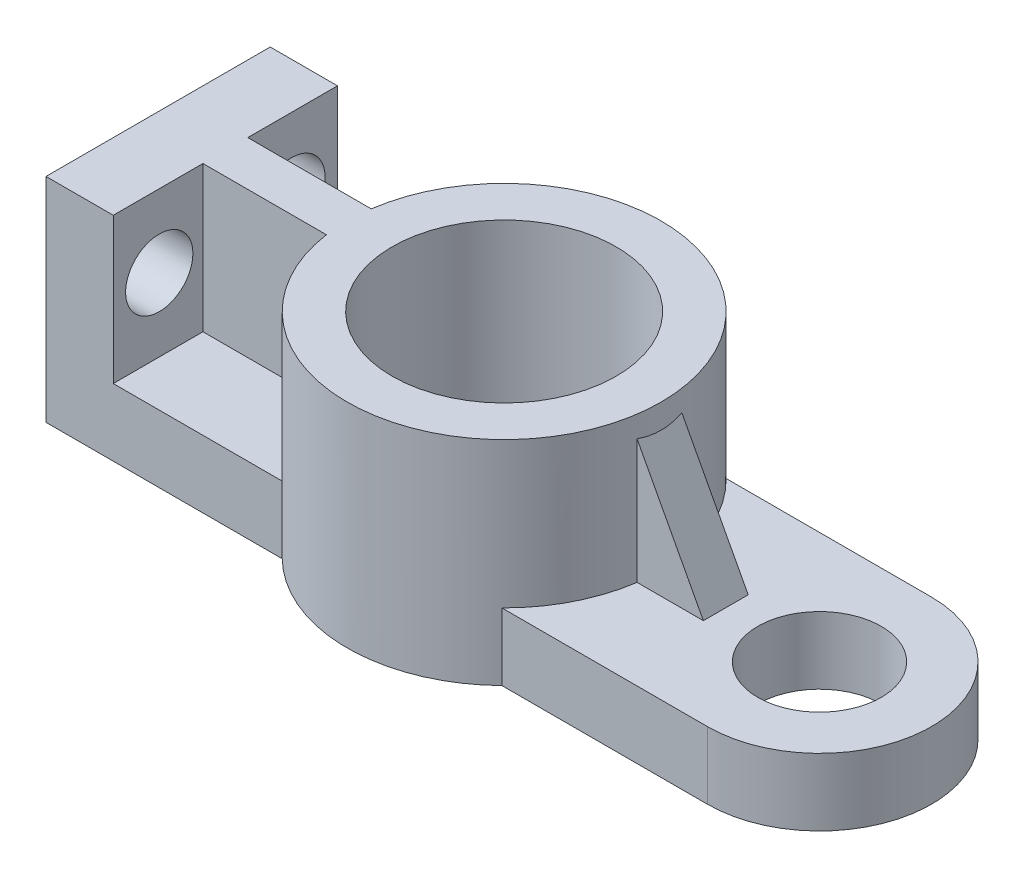
from build123d import *

# Parameters (mm, degrees)
EXTRUDE_THIN1_DEPTH      = 100
SKETCH2_W                = 50
SKETCH2_H                = 30
REVOLVE1_ANGLE           = 180
SKETCH3_R                = 27.5
CUT_EXTRUDE1_DEPTH       = 351.89172119
CUT_EXTRUDE1_DEPTH_BACK  = 351.89172119
SKETCH4_R                = 70
BOSS_EXTRUDE1_DEPTH      = 65
BOSS_EXTRUDE1_DEPTH_BACK = 30
SKETCH5_R                = 50
CUT_EXTRUDE2_DEPTH       = 364.765034054
SKETCH6_R                = 15
CUT_EXTRUDE3_DEPTH       = 347.446244026
RIB1_REACH               = 348.699
SKETCH8_WALL_W           = 749.740096374
SKETCH8_WALL_H           = 20
RIB23_REACH              = 348.699
SKETCH15_WALL_W          = 778.361425474
SKETCH15_WALL_H          = 20


with BuildPart() as part:
    # Sketch1 → Extrude-Thin1 (new body)
    with BuildSketch(Plane.XY):
        Polygon((-15, 80), (-15, -15), (280, -15), (280, 15), (15, 15), (15, 80), align=None)
    extrude(amount=EXTRUDE_THIN1_DEPTH)

    # Sketch2 → Revolve1 (revolve)
    with BuildSketch(Plane(origin=(280, 0, 0), x_dir=(0, 0, -1), z_dir=(1, 0, 0))):
        with Locations((-75, 0)):
            Rectangle(SKETCH2_W, SKETCH2_H)
    revolve(axis=Axis((280, 15, 50), (0, 1, 0)), revolution_arc=REVOLVE1_ANGLE)

    # Sketch3 → Cut-Extrude1 (cut, two sides)
    with BuildSketch(Plane(origin=(0, 15, 0), x_dir=(1, 0, 0), z_dir=(0, 1, 0))) as cut_extrude1_sk:
        with Locations(Location((280, -50, 0), (0, 0, 270))):
            Circle(SKETCH3_R)
    extrude(amount=CUT_EXTRUDE1_DEPTH, mode=Mode.SUBTRACT)
    extrude(cut_extrude1_sk.sketch, amount=-CUT_EXTRUDE1_DEPTH_BACK, mode=Mode.SUBTRACT)

    # Sketch4 → Boss-Extrude1 (add, two sides)
    with BuildSketch(Plane(origin=(0, 15, 0), x_dir=(1, 0, 0), z_dir=(0, 1, 0))) as boss_extrude1_sk:
        with Locations(Location((139.34266344, -50, 0), (0, 0, 270))):
            Circle(SKETCH4_R)
    extrude(amount=BOSS_EXTRUDE1_DEPTH)
    extrude(boss_extrude1_sk.sketch, amount=-BOSS_EXTRUDE1_DEPTH_BACK)

    # Sketch5 → Cut-Extrude2 (cut, through all)
    with BuildSketch(Plane(origin=(0, 80, 0), x_dir=(1, 0, 0), z_dir=(0, 1, 0))):
        with Locations(Location((139.34266344, -50, 0), (0, 0, 270))):
            Circle(SKETCH5_R)
    extrude(amount=-CUT_EXTRUDE2_DEPTH, mode=Mode.SUBTRACT)

    # Sketch6 → Cut-Extrude3 (cut, through all)
    with BuildSketch(Plane(origin=(15, 0, 0), x_dir=(0, 0, -1), z_dir=(1, 0, 0))):
        with Locations((-79.487733911, 47.5)):
            Circle(SKETCH6_R)
        with Locations(Location((-20.512266089, 47.5, 0), (0, 0, 180))):
            Circle(SKETCH6_R)
    extrude(amount=-CUT_EXTRUDE3_DEPTH, mode=Mode.SUBTRACT)

    # Sketch8 wall → Rib1 (add, up to next)
    with BuildSketch(Plane(origin=(42.17133172, 80, 50), x_dir=(1, 0, 0), z_dir=(0, 1, 0)), mode=Mode.PRIVATE) as rib1_sk1:
        Rectangle(SKETCH8_WALL_W, SKETCH8_WALL_H)
    rib1_tool1 = extrude(rib1_sk1.sketch, amount=-RIB1_REACH, mode=Mode.PRIVATE) - part.part
    add(rib1_tool1.solids().sort_by_distance((42.17133172, 80, 50))[0])

    # Sketch15 wall → Rib23 (add, up to next)
    with BuildSketch(Plane(origin=(223.056644771, 43.396320835, 50), x_dir=(0.470501542113, -0.88239917207, 0), z_dir=(0.88239917207, 0.470501542113, 0)), mode=Mode.PRIVATE) as rib23_sk1:
        Rectangle(SKETCH15_WALL_W, SKETCH15_WALL_H)
    rib23_tool1 = extrude(rib23_sk1.sketch, amount=-RIB23_REACH, mode=Mode.PRIVATE) - part.part
    add(rib23_tool1.solids().sort_by_distance((223.056644771, 43.396320835, 50))[0])


solid = part.part
